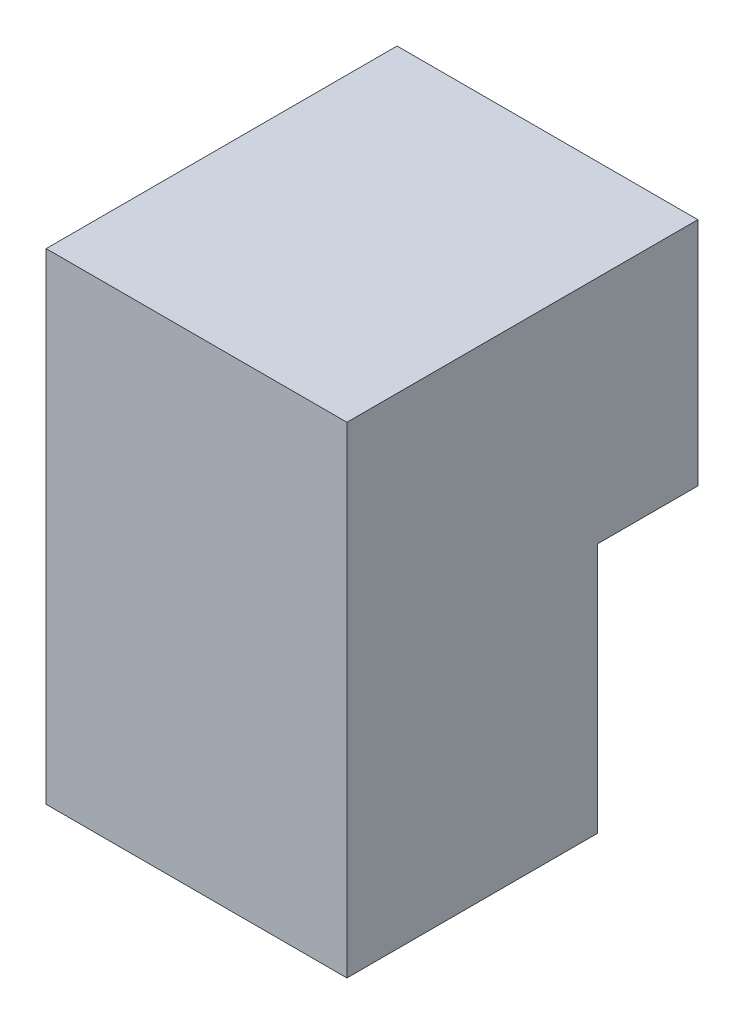
from build123d import *

# Parameters (mm, degrees)
BOSS_EXTRUDE1_DEPTH = 30


with BuildPart() as part:
    # Sketch1 → Boss-Extrude1 (new body)
    with BuildSketch(Plane.YZ):
        Polygon((1, -7.5), (1, -17.5), (24, -17.5), (24, 17.5), (-24, 17.5), (-24, -7.5), align=None)
    extrude(amount=BOSS_EXTRUDE1_DEPTH)


solid = part.part
